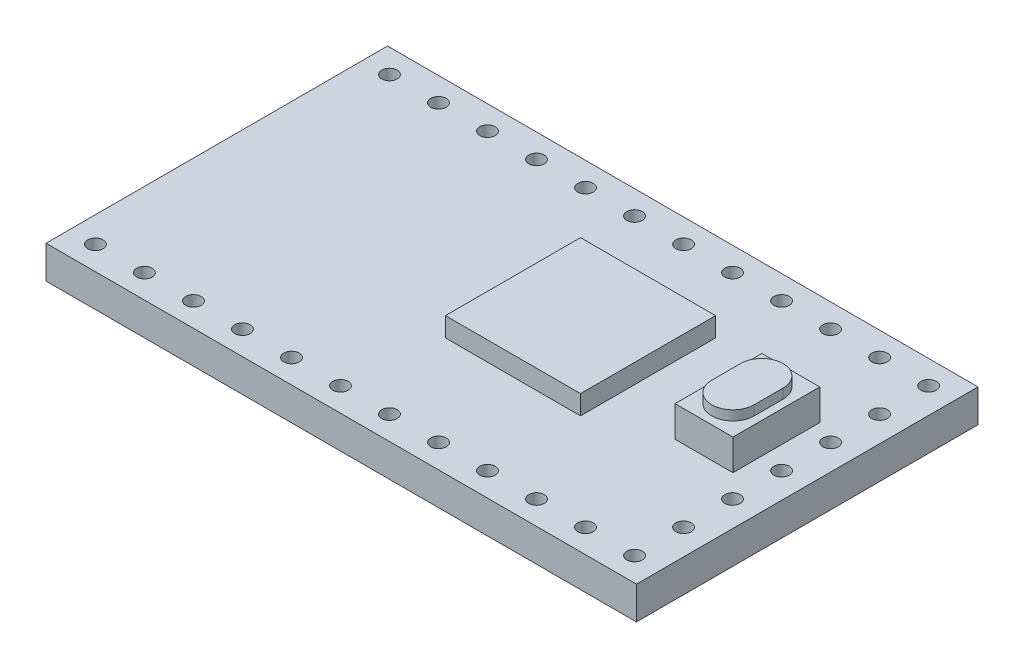
from build123d import *

# Parameters (mm, degrees)
ESQUISSE1_W             = 30.6
ESQUISSE1_H             = 17.7
BOSS_EXTRU_1_DEPTH      = 1.7
ESQUISSE2_W             = 7
ESQUISSE2_H             = 7
BOSS_EXTRU_2_DEPTH      = 1
ESQUISSE3_R             = 0.4
ENL_V_MAT_EXTRU_1_DEPTH = 3.7
ESQUISSE4_W             = 3
ESQUISSE4_H             = 4.5
BOSS_EXTRU_3_DEPTH      = 1.6
BOSS_EXTRU_4_DEPTH      = 0.5


with BuildPart() as part:
    # Esquisse1 → Boss.-Extru.1 (new body)
    with BuildSketch(Plane(origin=(0, 0, 0), x_dir=(1, 0, 0), z_dir=(0, 1, 0))):
        Rectangle(ESQUISSE1_W, ESQUISSE1_H)
    extrude(amount=BOSS_EXTRU_1_DEPTH)

    # Esquisse2 → Boss.-Extru.2 (add)
    with BuildSketch(Plane(origin=(0, 1.7, 0), x_dir=(1, 0, 0), z_dir=(0, 1, 0))):
        with Locations((2.8, 0.75)):
            Rectangle(ESQUISSE2_W, ESQUISSE2_H)
    extrude(amount=BOSS_EXTRU_2_DEPTH)

    # Esquisse3 → Enlèv. mat.-Extru.1 (cut, through all)
    with BuildSketch(Plane.XZ):
        with Locations((-13.97, -7.62)):
            Circle(ESQUISSE3_R)
        with Locations((-11.43, -7.62)):
            Circle(ESQUISSE3_R)
        with Locations((-8.89, -7.62)):
            Circle(ESQUISSE3_R)
        with Locations((-6.35, -7.62)):
            Circle(ESQUISSE3_R)
        with Locations((-3.81, -7.62)):
            Circle(ESQUISSE3_R)
        with Locations((-1.27, -7.62)):
            Circle(ESQUISSE3_R)
        with Locations((1.27, -7.62)):
            Circle(ESQUISSE3_R)
        with Locations((3.81, -7.62)):
            Circle(ESQUISSE3_R)
        with Locations((6.35, -7.62)):
            Circle(ESQUISSE3_R)
        with Locations((8.89, -7.62)):
            Circle(ESQUISSE3_R)
        with Locations((11.43, -7.62)):
            Circle(ESQUISSE3_R)
        with Locations((13.97, -7.62)):
            Circle(ESQUISSE3_R)
        with Locations((13.97, -5.08)):
            Circle(ESQUISSE3_R)
        with Locations((13.97, -2.54)):
            Circle(ESQUISSE3_R)
        with Locations((13.97, 0)):
            Circle(ESQUISSE3_R)
        with Locations((13.97, 2.54)):
            Circle(ESQUISSE3_R)
        with Locations((13.97, 5.08)):
            Circle(ESQUISSE3_R)
        with Locations((13.97, 7.62)):
            Circle(ESQUISSE3_R)
        with Locations((11.43, 7.62)):
            Circle(ESQUISSE3_R)
        with Locations((8.89, 7.62)):
            Circle(ESQUISSE3_R)
        with Locations((6.35, 7.62)):
            Circle(ESQUISSE3_R)
        with Locations((3.81, 7.62)):
            Circle(ESQUISSE3_R)
        with Locations((1.27, 7.62)):
            Circle(ESQUISSE3_R)
        with Locations((-1.27, 7.62)):
            Circle(ESQUISSE3_R)
        with Locations((-3.81, 7.62)):
            Circle(ESQUISSE3_R)
        with Locations((-6.35, 7.62)):
            Circle(ESQUISSE3_R)
        with Locations((-8.89, 7.62)):
            Circle(ESQUISSE3_R)
        with Locations((-11.43, 7.62)):
            Circle(ESQUISSE3_R)
        with Locations((-13.97, 7.62)):
            Circle(ESQUISSE3_R)
    extrude(amount=-ENL_V_MAT_EXTRU_1_DEPTH, mode=Mode.SUBTRACT)

    # Esquisse4 → Boss.-Extru.3 (add)
    with BuildSketch(Plane(origin=(0, 1.7, 0), x_dir=(1, 0, 0), z_dir=(0, 1, 0))):
        with Locations((11.3, 0.9)):
            Rectangle(ESQUISSE4_W, ESQUISSE4_H)
    extrude(amount=BOSS_EXTRU_3_DEPTH)

    # Esquisse5 → Boss.-Extru.4 (add)
    with BuildSketch(Plane(origin=(0, 3.3, 0), x_dir=(1, 0, 0), z_dir=(0, 1, 0))):
        with BuildLine():
            Line((12.4, 1.65), (12.4, 0.15))
            ThreePointArc((12.4, 0.15), (11.3, -0.95), (10.2, 0.15))
            Line((10.2, 0.15), (10.2, 1.65))
            ThreePointArc((10.2, 1.65), (11.3, 2.75), (12.4, 1.65))
        make_face()
    extrude(amount=BOSS_EXTRU_4_DEPTH)


solid = part.part
